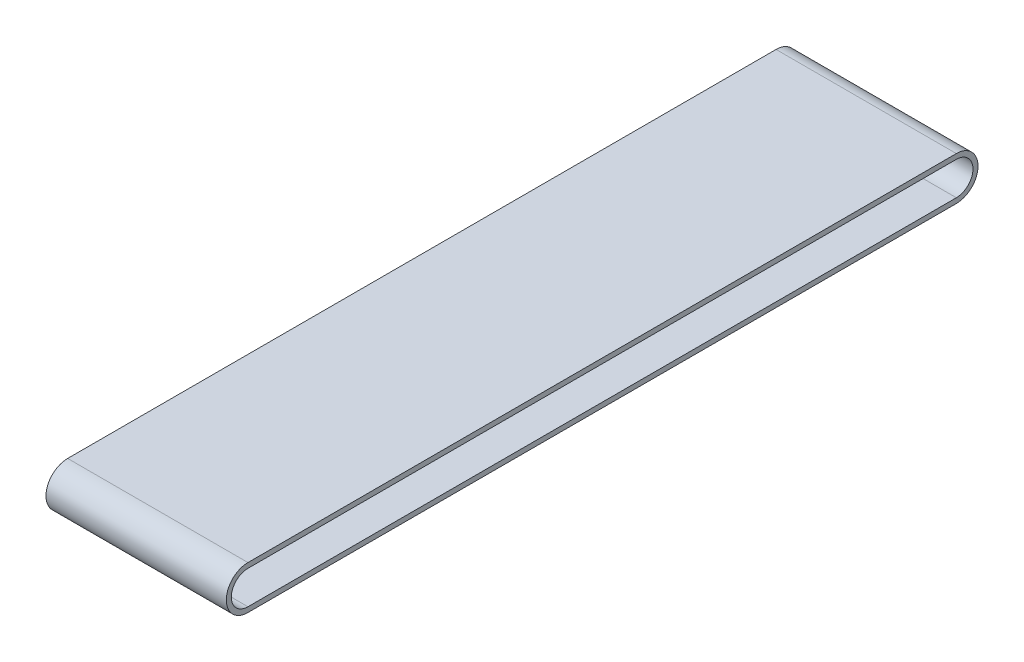
from build123d import *

# Parameters (mm, degrees)
BOSS_EXTRUDE1_DEPTH = 250


with BuildPart() as part:
    # Sketch1 → Boss-Extrude1 (new body)
    with BuildSketch(Plane(origin=(0, 0, 0), x_dir=(0, 0, -1), z_dir=(1, 0, 0))):
        with BuildLine():
            Line((513.239792121, -26.658071436), (-469.039237008, -26.658071436))
            ThreePointArc((-469.039237008, -26.658071436), (-499.068841475, 3.371533031), (-469.039237008, 33.401137498))
            Line((-469.039237008, 33.401137498), (513.239792121, 33.401137498))
            ThreePointArc((513.239792121, 33.401137498), (543.269396588, 3.371533031), (513.239792121, -26.658071436))
        make_face()
        with BuildLine():
            Line((-469.039237008, 26.421216111), (513.239792121, 26.421216111))
            ThreePointArc((513.239792121, 26.421216111), (536.2894752, 3.371533031), (513.239792121, -19.678150049))
            Line((513.239792121, -19.678150049), (-469.039237008, -19.678150049))
            ThreePointArc((-469.039237008, -19.678150049), (-492.088920087, 3.371533031), (-469.039237008, 26.421216111))
        make_face(mode=Mode.SUBTRACT)
    extrude(amount=BOSS_EXTRUDE1_DEPTH)


solid = part.part
